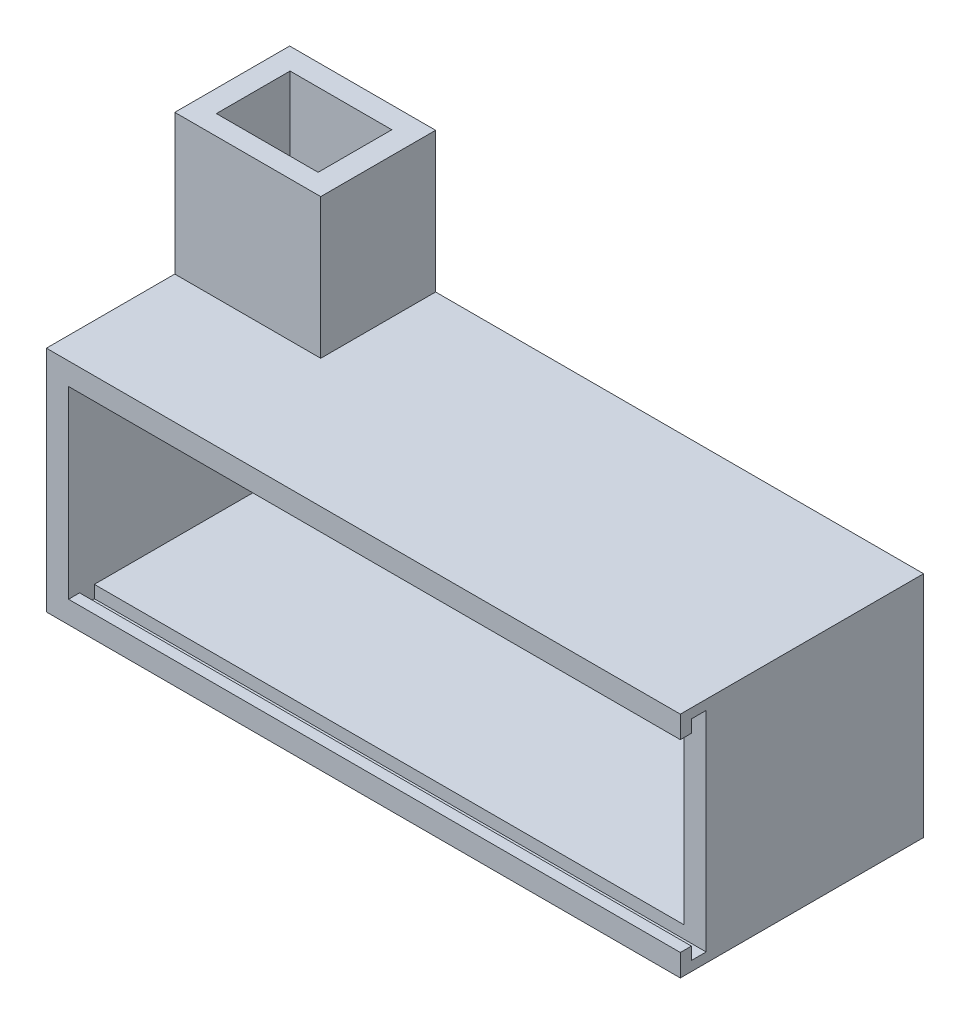
from build123d import *

# Parameters (mm, degrees)
ESQUISSE1_W             = 80
ESQUISSE1_H             = 25
BOSS_EXTRU_1_DEPTH      = 4
ESQUISSE3_W             = 80
ESQUISSE3_H             = 3
BOSS_EXTRU_2_DEPTH      = 28
ESQUISSE4_W             = 28
ESQUISSE4_H             = 31
BOSS_EXTRU_3_DEPTH      = 3
ESQUISSE5_W             = 28
ESQUISSE5_H             = 31
BOSS_EXTRU_4_DEPTH      = 3
BOSS_EXTRU_5_DEPTH      = 86
ESQUISSE7_W             = 5
ESQUISSE7_H             = 3
BOSS_EXTRU_6_DEPTH      = 3
ESQUISSE8_W             = 3
ESQUISSE8_H             = 5
BOSS_EXTRU_7_DEPTH      = 25
ESQUISSE10_W            = 3
ESQUISSE10_H            = 25
BOSS_EXTRU_8_DEPTH      = 1.5
ESQUISSE11_W            = 19.800437916
ESQUISSE11_H            = 15.586484264
ESQUISSE11_W_2          = 13.800437916
ESQUISSE11_H_2          = 10
BOSS_EXTRU_9_DEPTH      = 19
ESQUISSE12_W            = 13.800437916
ESQUISSE12_H            = 10
ENL_V_MAT_EXTRU_1_DEPTH = 3


with BuildPart() as part:
    # Esquisse1 → Boss.-Extru.1 (new body)
    with BuildSketch(Plane.XY):
        with Locations((-40, 12.5)):
            Rectangle(ESQUISSE1_W, ESQUISSE1_H)
    extrude(amount=BOSS_EXTRU_1_DEPTH)

    # Esquisse3 → Boss.-Extru.2 (add)
    with BuildSketch(Plane(origin=(0, 0, 0), x_dir=(-1, 0, 0), z_dir=(0, 0, -1))):
        with Locations((40, -1.5)):
            Rectangle(ESQUISSE3_W, ESQUISSE3_H)
    boss_extru_2 = extrude(amount=-BOSS_EXTRU_2_DEPTH)

    # Symétrie1: Boss.-Extru.2 across plane
    add(boss_extru_2.mirror(Plane.ZX.offset(12.5)))

    # Esquisse4 → Boss.-Extru.3 (add)
    with BuildSketch(Plane(origin=(0, 0, 0), x_dir=(0, 0, -1), z_dir=(1, 0, 0))):
        with Locations((-14, 12.5)):
            Rectangle(ESQUISSE4_W, ESQUISSE4_H)
    extrude(amount=BOSS_EXTRU_3_DEPTH)

    # Esquisse5 → Boss.-Extru.4 (add)
    with BuildSketch(Plane.ZY.offset(80)):
        with Locations((14, 12.5)):
            Rectangle(ESQUISSE5_W, ESQUISSE5_H)
    extrude(amount=BOSS_EXTRU_4_DEPTH)

    # Esquisse6 → Boss.-Extru.5 (add)
    with BuildSketch(Plane(origin=(3, 0, 0), x_dir=(0, 0, -1), z_dir=(1, 0, 0))):
        Polygon((-31.5, 0), (-33, 0), (-33, -3), (-28, -3), (-28, 0), (-29.5, 0), (-29.5, -1.691160161), (-31.5, -1.691160161), align=None)
    boss_extru_5 = extrude(amount=-BOSS_EXTRU_5_DEPTH)

    # Esquisse7 → Boss.-Extru.6 (add)
    with BuildSketch(Plane.ZY.offset(83)):
        with Locations((30.5, -1.5)):
            Rectangle(ESQUISSE7_W, ESQUISSE7_H)
    boss_extru_6 = extrude(amount=-BOSS_EXTRU_6_DEPTH)

    # Symétrie2: Boss.-Extru.5, Boss.-Extru.6 across plane
    add(boss_extru_5.mirror(Plane.ZX.offset(12.5)))
    add(boss_extru_6.mirror(Plane.ZX.offset(12.5)))

    # Esquisse8 → Boss.-Extru.7 (add)
    with BuildSketch(Plane.XZ.offset(-25)):
        with Locations((-81.5, 30.5)):
            Rectangle(ESQUISSE8_W, ESQUISSE8_H)
    extrude(amount=BOSS_EXTRU_7_DEPTH)

    # Esquisse10 → Boss.-Extru.8 (add)
    with BuildSketch(Plane.XY.offset(28)):
        with Locations((1.5, 12.5)):
            Rectangle(ESQUISSE10_W, ESQUISSE10_H)
    extrude(amount=BOSS_EXTRU_8_DEPTH)

    # Esquisse11 → Boss.-Extru.9 (add)
    with BuildSketch(Plane(origin=(0, 28, 0), x_dir=(1, 0, 0), z_dir=(0, 1, 0))):
        with Locations((-73.099781042, -7.793242132)):
            Rectangle(ESQUISSE11_W, ESQUISSE11_H)
        with Locations((-73.131327902, -7.910815451)):
            Rectangle(ESQUISSE11_W_2, ESQUISSE11_H_2, mode=Mode.SUBTRACT)
    extrude(amount=BOSS_EXTRU_9_DEPTH)

    # Esquisse12 → Enlèv. mat.-Extru.1 (cut)
    with BuildSketch(Plane(origin=(0, 28, 0), x_dir=(1, 0, 0), z_dir=(0, 1, 0))):
        with Locations((-73.131327902, -7.910815451)):
            Rectangle(ESQUISSE12_W, ESQUISSE12_H)
    extrude(amount=-ENL_V_MAT_EXTRU_1_DEPTH, mode=Mode.SUBTRACT)


solid = part.part
